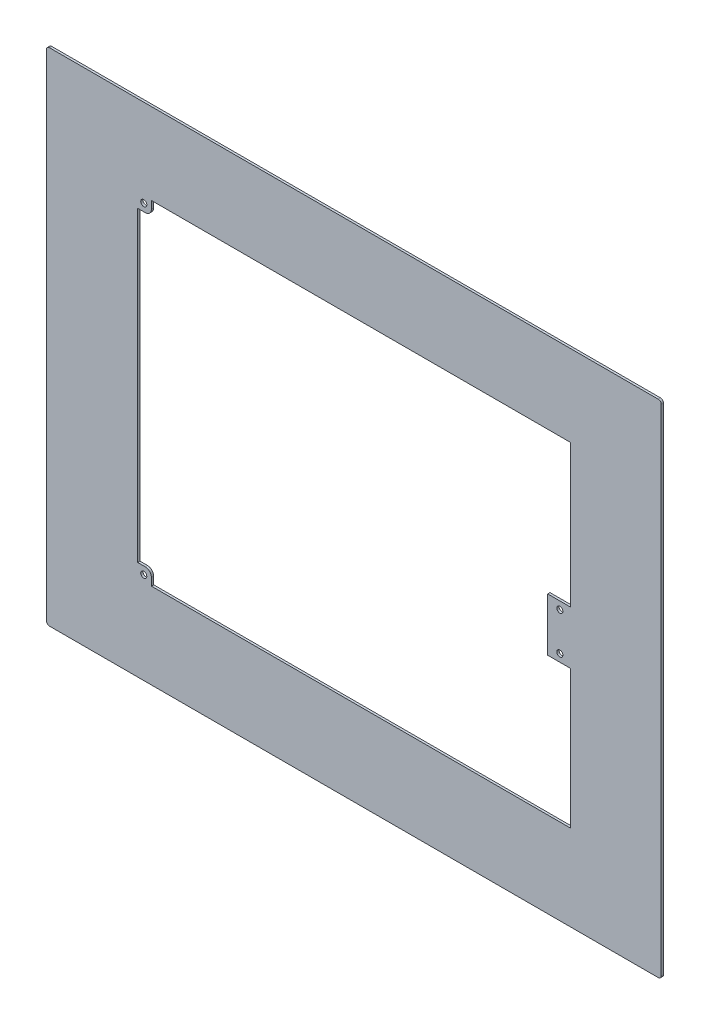
from build123d import *

# Parameters (mm, degrees)
SKETCH1_W           = 405
SKETCH1_H           = 330
BOSS_EXTRUDE1_DEPTH = 1.5
SKETCH2_W           = 285.12
SKETCH2_H           = 220.03
CUT_EXTRUDE1_DEPTH  = 2.5
SKETCH3_W           = 9
SKETCH3_H           = 9
SKETCH3_W_2         = 15
SKETCH3_H_2         = 35
BOSS_EXTRUDE2_DEPTH = 1.5
SKETCH4_R           = 2
CUT_EXTRUDE2_DEPTH  = 2.5
FILLET1_R           = 4
FILLET2_R           = 2


with BuildPart() as part:
    # Sketch1 → Boss-Extrude1 (new body)
    with BuildSketch(Plane.XY):
        Rectangle(SKETCH1_W, SKETCH1_H)
    extrude(amount=BOSS_EXTRUDE1_DEPTH)

    # Sketch2 → Cut-Extrude1 (cut, through all)
    with BuildSketch(Plane.XY.offset(1.5)):
        with Locations((0.15, 1.415)):
            Rectangle(SKETCH2_W, SKETCH2_H)
    extrude(amount=-CUT_EXTRUDE1_DEPTH, mode=Mode.SUBTRACT)

    # Sketch3 → Boss-Extrude2 (add)
    with BuildSketch(Plane.XY.offset(1.5)):
        with Locations((-137.91, 106.93)):
            Rectangle(SKETCH3_W, SKETCH3_H)
        with Locations((-137.91, -104.1)):
            Rectangle(SKETCH3_W, SKETCH3_H)
        with Locations((135.21, 0)):
            Rectangle(SKETCH3_W_2, SKETCH3_H_2)
    extrude(amount=-BOSS_EXTRUDE2_DEPTH)

    # Sketch4 → Cut-Extrude2 (cut, through all)
    with BuildSketch(Plane.XY.offset(1.5)):
        with Locations((-138.41, 107.43)):
            Circle(SKETCH4_R)
        with Locations((-138.41, -104.6)):
            Circle(SKETCH4_R)
        with Locations((135.71, 12.5)):
            Circle(SKETCH4_R)
        with Locations((135.71, -12.5)):
            Circle(SKETCH4_R)
    extrude(amount=-CUT_EXTRUDE2_DEPTH, mode=Mode.SUBTRACT)

    # Fillet1
    fillet1_edges = [part.edges().sort_by_distance(p)[0] for p in [
        (-133.41, 102.43, 0.75),
        (-133.41, -99.6, 0.75),
    ]]
    fillet(fillet1_edges, radius=FILLET1_R)

    # Fillet2
    fillet2_edges = [part.edges().sort_by_distance(p)[0] for p in [
        (202.5, -165, 0.75),
        (-202.5, -165, 0.75),
        (-202.5, 165, 0.75),
        (202.5, 165, 0.75),
    ]]
    fillet(fillet2_edges, radius=FILLET2_R)


solid = part.part
